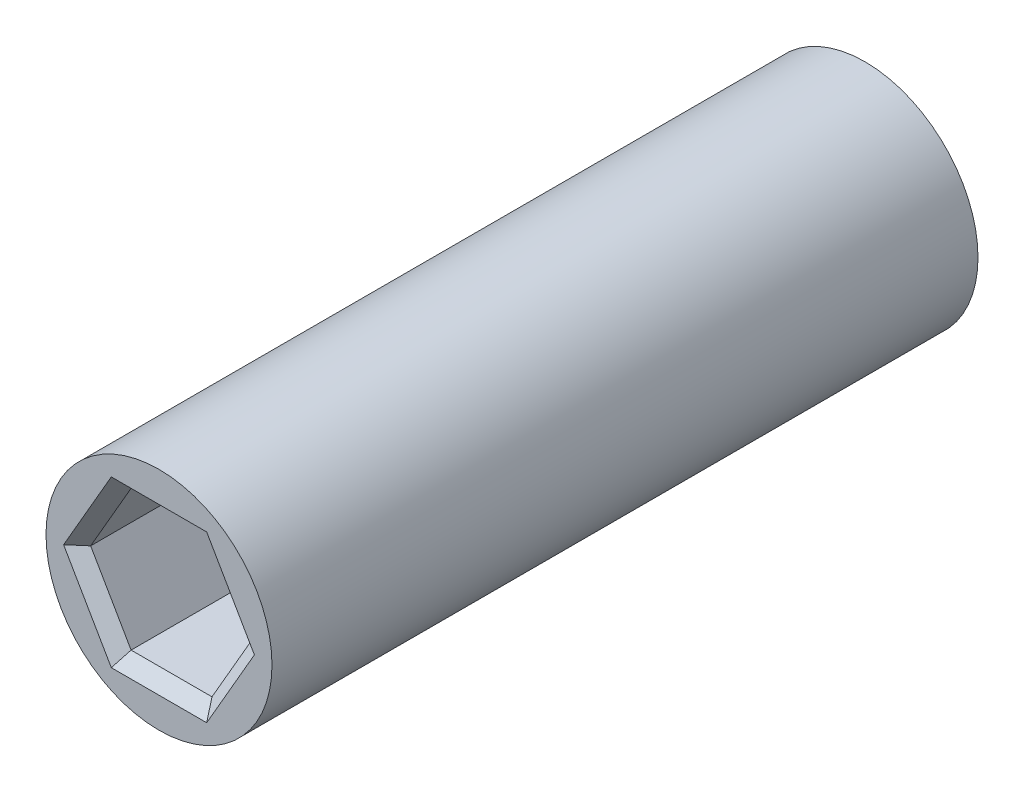
from build123d import *

# Parameters (mm, degrees)
SKETCH1_W          = 4.5
SKETCH1_H          = 28.11709914
CUT_EXTRUDE1_DEPTH = 7
CUT_EXTRUDE2_DEPTH = 7
CHAMFER1_SIZE      = 0.5


with BuildPart() as part:
    # Sketch1 → Revolve-Thin1 (revolve)
    with BuildSketch(Plane(origin=(0, 0, 0), x_dir=(1, 0, 0), z_dir=(0, 1, 0))):
        with Locations((2.25, 31.55854957)):
            Rectangle(SKETCH1_W, SKETCH1_H)
    revolve(axis=Axis((0, 0, 0), (0, 0, -1)))

    # Sketch2 → Cut-Extrude1 (cut)
    with BuildSketch(Plane.XY.offset(-17.5)):
        Polygon((1.610807251, 2.79), (-1.610807251, 2.79), (-3.221614502, 0), (-1.610807251, -2.79), (1.610807251, -2.79), (3.221614502, 0), align=None)
    extrude(amount=-CUT_EXTRUDE1_DEPTH, mode=Mode.SUBTRACT)

    # Sketch3 → Cut-Extrude2 (cut)
    with BuildSketch(Plane(origin=(0, 0, -45.61709914), x_dir=(-1, 0, 0), z_dir=(0, 0, -1))):
        Polygon((1.610807251, 2.79), (-1.610807251, 2.79), (-3.221614502, 0), (-1.610807251, -2.79), (1.610807251, -2.79), (3.221614502, 0), align=None)
    extrude(amount=-CUT_EXTRUDE2_DEPTH, mode=Mode.SUBTRACT)

    # Chamfer1
    chamfer1_edges = [part.edges().sort_by_distance(p)[0] for p in [
        (2.416210877, 1.395, -17.5),
        (0, 2.79, -17.5),
        (-2.416210877, 1.395, -17.5),
        (-2.416210877, -1.395, -17.5),
        (0, -2.79, -17.5),
        (2.416210877, -1.395, -17.5),
        (-2.416210877, 1.395, -45.61709914),
        (0, 2.79, -45.61709914),
        (2.416210877, 1.395, -45.61709914),
        (2.416210877, -1.395, -45.61709914),
        (0, -2.79, -45.61709914),
        (-2.416210877, -1.395, -45.61709914),
    ]]
    chamfer(chamfer1_edges, length=CHAMFER1_SIZE)


solid = part.part
